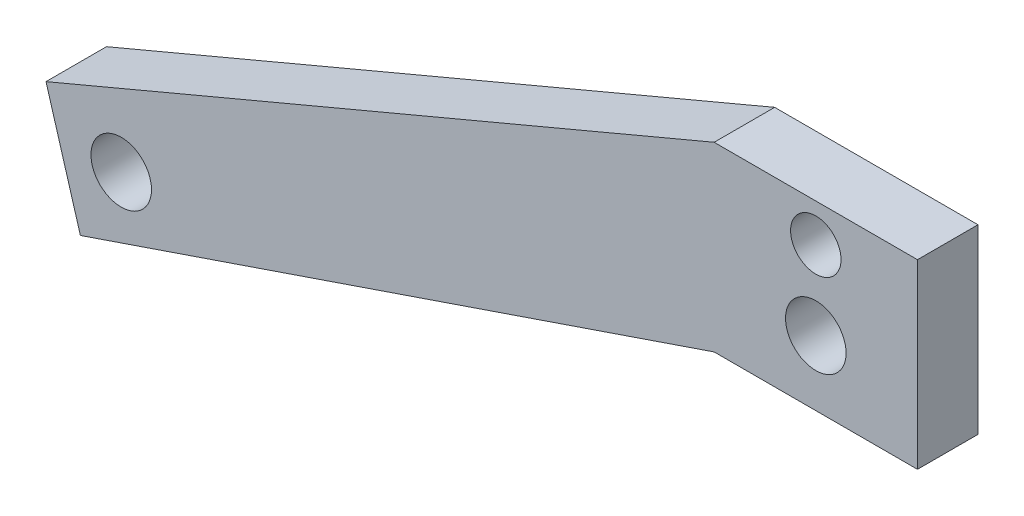
from build123d import *

# Parameters (mm, degrees)
SKETCH1_R           = 3.96875
SKETCH1_R_2         = 4.762500002
BOSS_EXTRUDE1_DEPTH = 9.525


with BuildPart() as part:
    # Sketch1 → Boss-Extrude1 (new body)
    with BuildSketch(Plane.XY):
        Polygon((-15.999993773, 44.99997758), (-121.1436315, 0.697282679), (-115.733139184, -17.56823327), (-15.999993773, 16.42497758), (16.000006227, 16.42497758), (16.000006227, 44.99997758), align=None)
        with Locations((6.227e-06, 38.99997758)):
            Circle(SKETCH1_R, mode=Mode.SUBTRACT)
        with Locations((6.239e-06, 26.647574613)):
            Circle(SKETCH1_R_2, mode=Mode.SUBTRACT)
        with Locations((-109.305627368, -5.730229137)):
            Circle(SKETCH1_R_2, mode=Mode.SUBTRACT)
    extrude(amount=BOSS_EXTRUDE1_DEPTH)


solid = part.part
